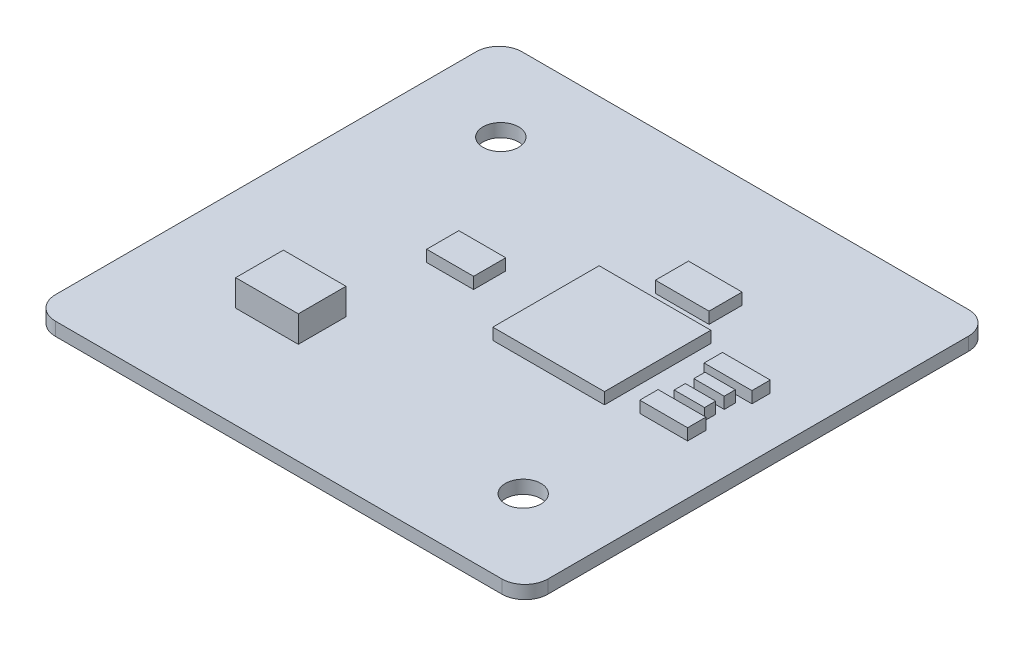
from build123d import *

# Parameters (mm, degrees)
BOSS_EXTRUDE1_DEPTH = 1.15
CUT_EXTRUDE1_REACH  = 3.15
SKETCH2_R           = 1.55
SKETCH3_W           = 5.45
SKETCH3_H           = 4.15
BOSS_EXTRUDE2_DEPTH = 2.3
SKETCH4_W           = 9.718661505
SKETCH4_H           = 9.252165754
SKETCH4_W_2         = 4.664957522
SKETCH4_H_2         = 2.876723805
SKETCH4_W_3         = 4.081837833
SKETCH4_H_3         = 2.798974514
SKETCH4_W_4         = 4.159587124
SKETCH4_H_4         = 1.593860487
SKETCH4_W_5         = 2.64347593
SKETCH4_H_5         = 0.971866151
BOSS_EXTRUDE3_DEPTH = 1


with BuildPart() as part:
    # Sketch1 → Boss-Extrude1 (new body)
    with BuildSketch(Plane(origin=(0, 0, 0), x_dir=(1, 0, 0), z_dir=(0, 1, 0))):
        with BuildLine():
            Line((-19.425, 20.3), (19.425, 20.3))
            ThreePointArc((19.425, 20.3), (20.839213562, 19.714213562), (21.425, 18.3))
            Line((21.425, 18.3), (21.425, -18.3))
            ThreePointArc((21.425, -18.3), (20.839213562, -19.714213562), (19.425, -20.3))
            Line((19.425, -20.3), (-19.425, -20.3))
            ThreePointArc((-19.425, -20.3), (-20.839213562, -19.714213562), (-21.425, -18.3))
            Line((-21.425, -18.3), (-21.425, 18.3))
            ThreePointArc((-21.425, 18.3), (-20.839213562, 19.714213562), (-19.425, 20.3))
        make_face()
    extrude(amount=BOSS_EXTRUDE1_DEPTH)

    # Sketch2 → Cut-Extrude1 (cut, up to next)
    with BuildSketch(Plane(origin=(0, 1.15, 0), x_dir=(1, 0, 0), z_dir=(0, 1, 0)), mode=Mode.PRIVATE) as cut_extrude1_sk1:
        with Locations((-13.925, 12.95)):
            Circle(SKETCH2_R)
    cut_extrude1_tool1 = extrude(cut_extrude1_sk1.sketch, amount=-CUT_EXTRUDE1_REACH, mode=Mode.PRIVATE) & part.part
    add(cut_extrude1_tool1.solids().sort_by_distance((-13.925, 1.15, -12.95))[0], mode=Mode.SUBTRACT)
    # Sketch2 → Cut-Extrude1 (cut, up to next)
    with BuildSketch(Plane(origin=(0, 1.15, 0), x_dir=(1, 0, 0), z_dir=(0, 1, 0)), mode=Mode.PRIVATE) as cut_extrude1_sk2:
        with Locations((13.925, -12.95)):
            Circle(SKETCH2_R)
    cut_extrude1_tool2 = extrude(cut_extrude1_sk2.sketch, amount=-CUT_EXTRUDE1_REACH, mode=Mode.PRIVATE) & part.part
    add(cut_extrude1_tool2.solids().sort_by_distance((13.925, 1.15, 12.95))[0], mode=Mode.SUBTRACT)

    # Sketch3 → Boss-Extrude2 (add)
    with BuildSketch(Plane(origin=(0, 1.15, 0), x_dir=(1, 0, 0), z_dir=(0, 1, 0))):
        with Locations((-9.84, -9.405)):
            Rectangle(SKETCH3_W, SKETCH3_H)
    extrude(amount=BOSS_EXTRUDE2_DEPTH)

    # Sketch4 → Boss-Extrude3 (add)
    with BuildSketch(Plane(origin=(0, 1.15, 0), x_dir=(1, 0, 0), z_dir=(0, 1, 0))):
        with Locations((5.908946196, 1.904857655)):
            Rectangle(SKETCH4_W, SKETCH4_H)
        with Locations((6.919686992, 9.329915045)):
            Rectangle(SKETCH4_W_2, SKETCH4_H_2)
        with Locations((-5.656260997, 1.671609779)):
            Rectangle(SKETCH4_W_3, SKETCH4_H_3)
        with Locations((15.025050688, 4.567770907)):
            Rectangle(SKETCH4_W_4, SKETCH4_H_4)
        with Locations((14.99993444, 2.629590434)):
            Rectangle(SKETCH4_W_5, SKETCH4_H_5)
        with Locations((14.99993444, 0.91910601)):
            Rectangle(SKETCH4_W_5, SKETCH4_H_5)
        with Locations((15.025050688, -1.030178119)):
            Rectangle(SKETCH4_W_4, SKETCH4_H_4)
    extrude(amount=BOSS_EXTRUDE3_DEPTH)


solid = part.part
